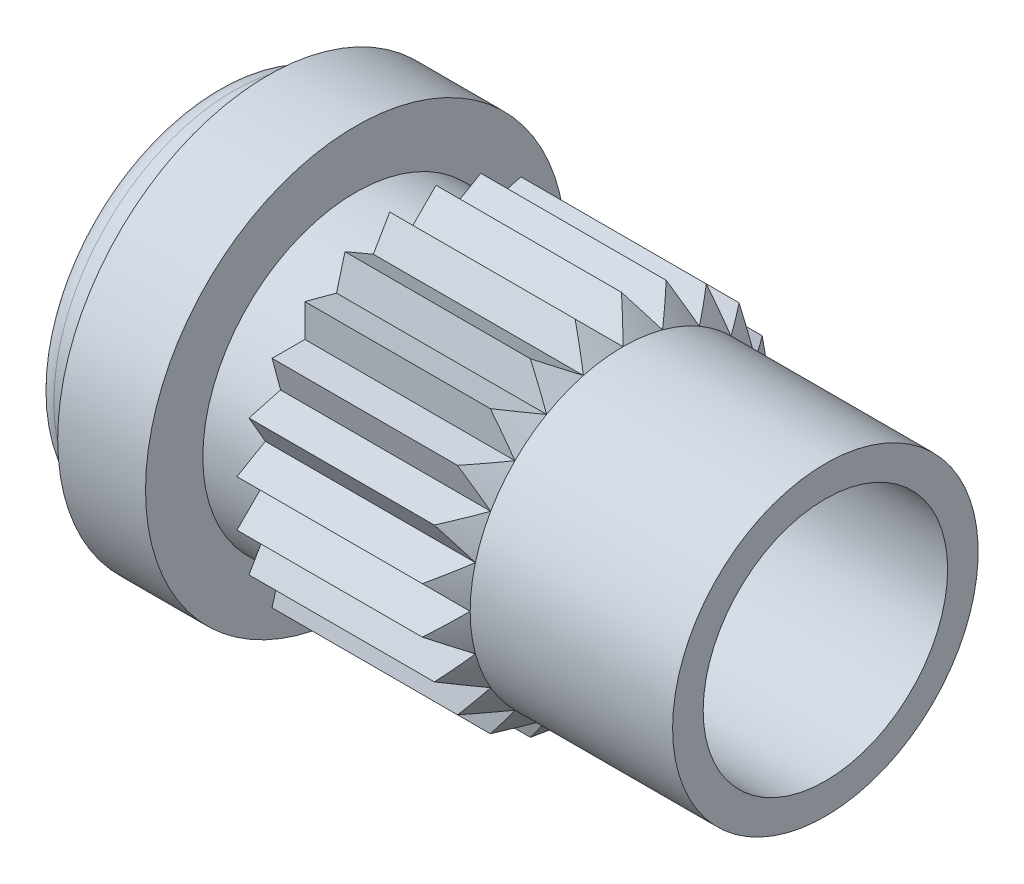
from build123d import *

# Parameters (mm, degrees)
HOLE1_D               = 1.6256
HOLE1_DEPTH           = 4.064
HOLE1_TIP             = 0.488379511
EXTRUSIONBLIND1_DEPTH = 1.397
POLAR_PATTERN1_COUNT  = 24


with BuildPart() as part:
    # Sketch1 → RevolutionAngle1 (revolve)
    with BuildSketch(Plane.XY):
        with BuildLine():
            Line((4.064, 0), (4.064, 1.016))
            Line((4.064, 1.016), (2.7178, 1.016))
            Line((2.7178, 1.016), (2.5527, 1.1811))
            Line((2.5527, 1.1811), (1.3208, 1.1811))
            Line((1.3208, 1.1811), (1.3208, 1.016))
            Line((1.3208, 1.016), (0.9398, 1.016))
            Line((0.9398, 1.016), (0.9398, 1.397))
            Line((0.9398, 1.397), (0.3556, 1.397))
            Line((0.3556, 1.397), (0.3556, 1.1938))
            Line((0.3556, 1.1938), (0.127, 1.1938))
            ThreePointArc((0.127, 1.1938), (0.037197439, 1.156602561), (0, 1.0668))
            Line((0, 1.0668), (0, 0))
            Line((0, 0), (4.064, 0))
        make_face()
    revolve(axis=Axis((0, 0, 0), (1, 0, 0)))

    # Hole1
    with Locations(Plane.ZY):
        with Locations((0, 0)):
            Hole(HOLE1_D / 2, depth=HOLE1_DEPTH)
            with Locations((0, 0, -(HOLE1_DEPTH + HOLE1_TIP / 2))):  # 118° drill point
                Cone(0, HOLE1_D / 2, HOLE1_TIP, mode=Mode.SUBTRACT)

    # Sketch4 → ExtrusionBlind1 (cut)
    with BuildSketch(Plane.ZY.offset(-1.3208)):
        Polygon((-1.016, 0), (-1.1811, -0.1651), (-1.1811, 0.1651), align=None)
    extrusionblind1 = extrude(amount=-EXTRUSIONBLIND1_DEPTH, mode=Mode.SUBTRACT)

    # Polar Pattern1: ExtrusionBlind1 ×24 about axis
    polar_pattern1_axis = Axis((0, 0, 0), (1, 0, 0))
    for i in range(1, POLAR_PATTERN1_COUNT):
        add(extrusionblind1.rotate(polar_pattern1_axis, i * 360 / POLAR_PATTERN1_COUNT), mode=Mode.SUBTRACT)


solid = part.part
